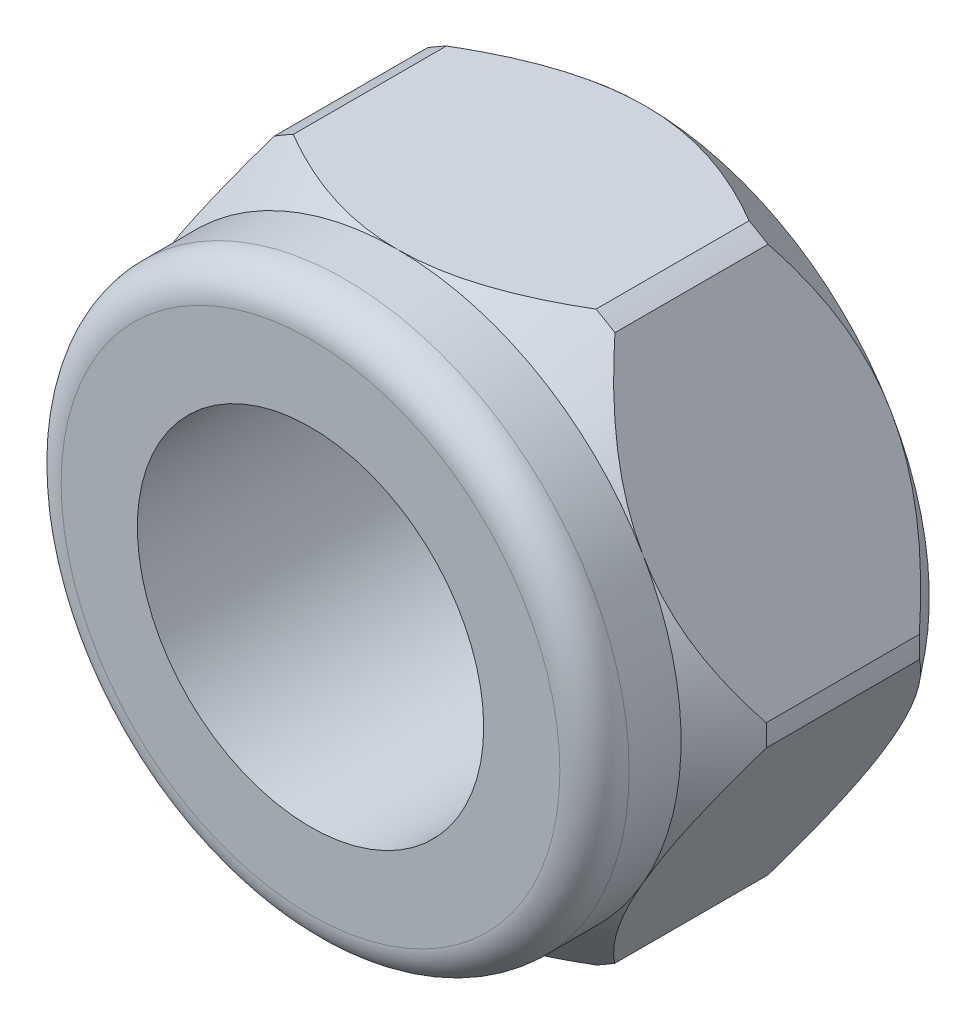
from build123d import *

# Parameters (mm, degrees)
SKETCH1_R           = 3
BOSS_EXTRUDE1_DEPTH = 4.3
SKETCH2_R           = 4.92
SKETCH2_R_2         = 3
BOSS_EXTRUDE2_DEPTH = 1.5
FILLET1_R           = 0.6
CHAMFER1_SIZE       = 0.3


with BuildPart() as part:
    # Sketch1 → Boss-Extrude1 (new body)
    with BuildSketch(Plane.XY):
        Polygon((-2.840563324, 4.92), (2.840563324, 4.92), (5.681126649, 0), (2.840563324, -4.92), (-2.840563324, -4.92), (-5.681126649, 0), align=None)
        Circle(SKETCH1_R, mode=Mode.SUBTRACT)
    extrude(amount=BOSS_EXTRUDE1_DEPTH)

    # Sketch2 → Boss-Extrude2 (add)
    with BuildSketch(Plane.XY.offset(4.3)):
        Circle(SKETCH2_R)
        Circle(SKETCH2_R_2, mode=Mode.SUBTRACT)
    extrude(amount=BOSS_EXTRUDE2_DEPTH)

    # Fillet1
    fillet1_edges = [part.edges().sort_by_distance(p)[0] for p in [
        (-4.92, 0, 5.8),
    ]]
    fillet(fillet1_edges, radius=FILLET1_R)

    # Sketch3 → Cut-Revolve1 (revolve, cut)
    with BuildSketch(Plane(origin=(0, 0, 0), x_dir=(0, 0, -1), z_dir=(1, 0, 0))):
        Polygon((-4.3, 4.92), (-3.475971619, 5.575), (-0.824028381, 5.575), (0, 4.92), (0, 6.412884747), (-4.3, 6.412884747), align=None)
    revolve(axis=Axis((0, 0, 0), (0, 0, -1)), mode=Mode.SUBTRACT)

    # Chamfer1
    chamfer1_edges = [part.edges().sort_by_distance(p)[0] for p in [
        (-3, 0, 0),
    ]]
    chamfer(chamfer1_edges, length=CHAMFER1_SIZE)


solid = part.part
